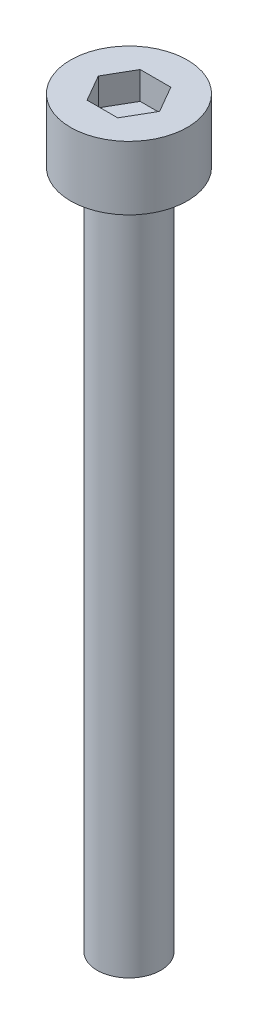
from build123d import *

# Parameters (mm, degrees)
SKETCH_1_R            = 2.75
EXTRUDE_248_DEPTH     = 3
CUT_EXTRUDE_378_DEPTH = 1.3
SKETCH_3_R            = 1.5
EXTRUDE_479_DEPTH     = 32


with BuildPart() as part:
    # 草图1 → Extrude 248 (new body)
    with BuildSketch(Plane(origin=(0, 0, 0), x_dir=(1, 0, 0), z_dir=(0, 1, 0))):
        Circle(SKETCH_1_R)
    extrude(amount=EXTRUDE_248_DEPTH)

    # 草图2 → Cut-Extrude 378 (cut)
    with BuildSketch(Plane(origin=(0, 3, 0), x_dir=(1, 0, 0), z_dir=(0, 1, 0))):
        Polygon((1.443375673, 0), (0.721687836, 1.25), (-0.721687836, 1.25), (-1.443375673, 0), (-0.721687836, -1.25), (0.721687836, -1.25), align=None)
    extrude(amount=-CUT_EXTRUDE_378_DEPTH, mode=Mode.SUBTRACT)

    # 草图3 → Extrude 479 (add)
    with BuildSketch(Plane.XZ):
        Circle(SKETCH_3_R)
    extrude(amount=EXTRUDE_479_DEPTH)


solid = part.part
